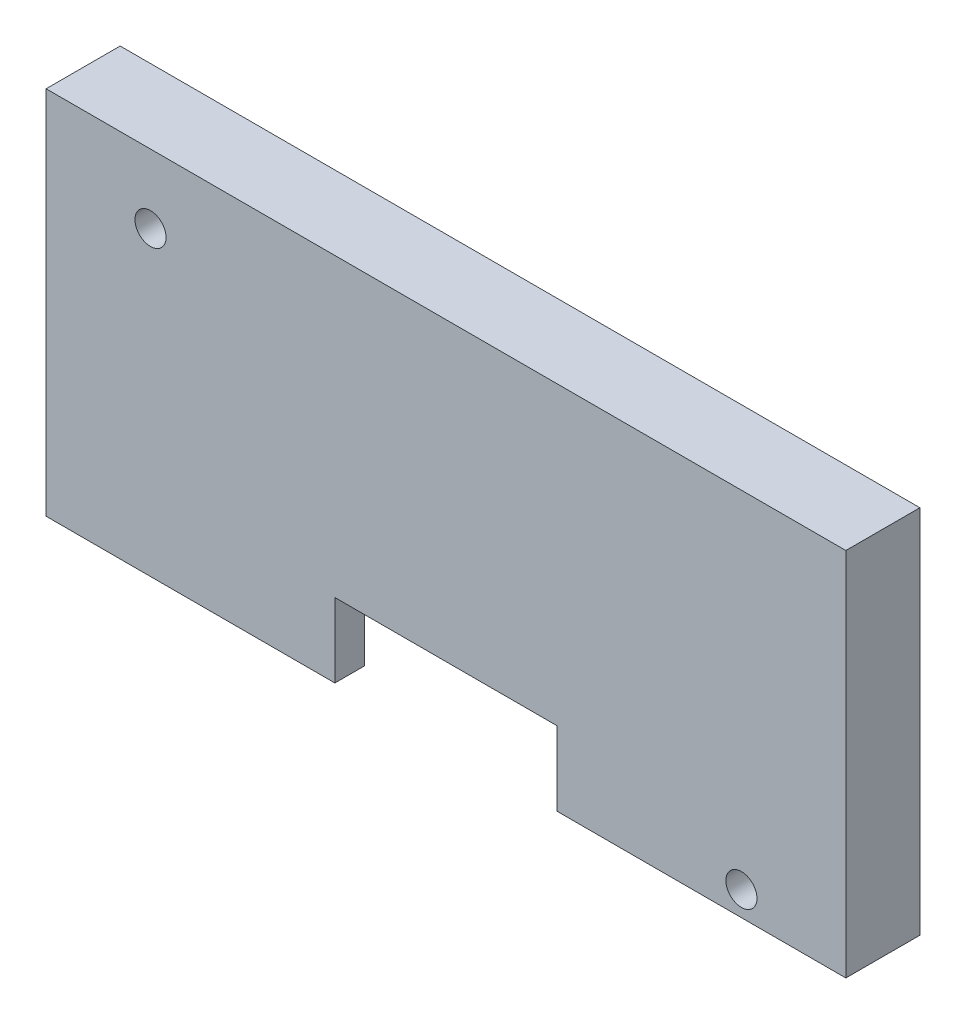
from build123d import *

# Parameters (mm, degrees)
SKETCH_1_W          = 54
SKETCH_1_H          = 25
EXTRUDE_1_DEPTH     = 5
SKETCH_2_W          = 50
SKETCH_2_H          = 22
CUT_EXTRUDE_1_DEPTH = 3
SKETCH_3_R          = 1.05
CUT_EXTRUDE_2_DEPTH = 17
SKETCH_4_W          = 15
SKETCH_4_H          = 5
CUT_EXTRUDE_3_DEPTH = 18


with BuildPart() as part:
    # 草圖1 → 填料-伸長1 (new body)
    with BuildSketch(Plane.XY):
        with Locations((10.036827119, -5.081562568)):
            Rectangle(SKETCH_1_W, SKETCH_1_H)
    extrude(amount=EXTRUDE_1_DEPTH)

    # 草圖2 → 除料-伸長1 (cut)
    with BuildSketch(Plane.XY):
        with Locations((10.036827119, -6.581562568)):
            Rectangle(SKETCH_2_W, SKETCH_2_H)
    extrude(amount=CUT_EXTRUDE_1_DEPTH, mode=Mode.SUBTRACT)

    # 草圖3 → 除料-伸長2 (cut)
    with BuildSketch(Plane.XY):
        with Locations((29.986827119, -15.931562568)):
            Circle(SKETCH_3_R)
        with Locations((-9.913172881, 2.768437432)):
            Circle(SKETCH_3_R)
    extrude(amount=CUT_EXTRUDE_2_DEPTH, mode=Mode.SUBTRACT)

    # 草圖4 → 除料-伸長3 (cut)
    with BuildSketch(Plane.XY):
        with Locations((10.036827119, -15.081562568)):
            Rectangle(SKETCH_4_W, SKETCH_4_H)
    extrude(amount=CUT_EXTRUDE_3_DEPTH, mode=Mode.SUBTRACT)


solid = part.part
